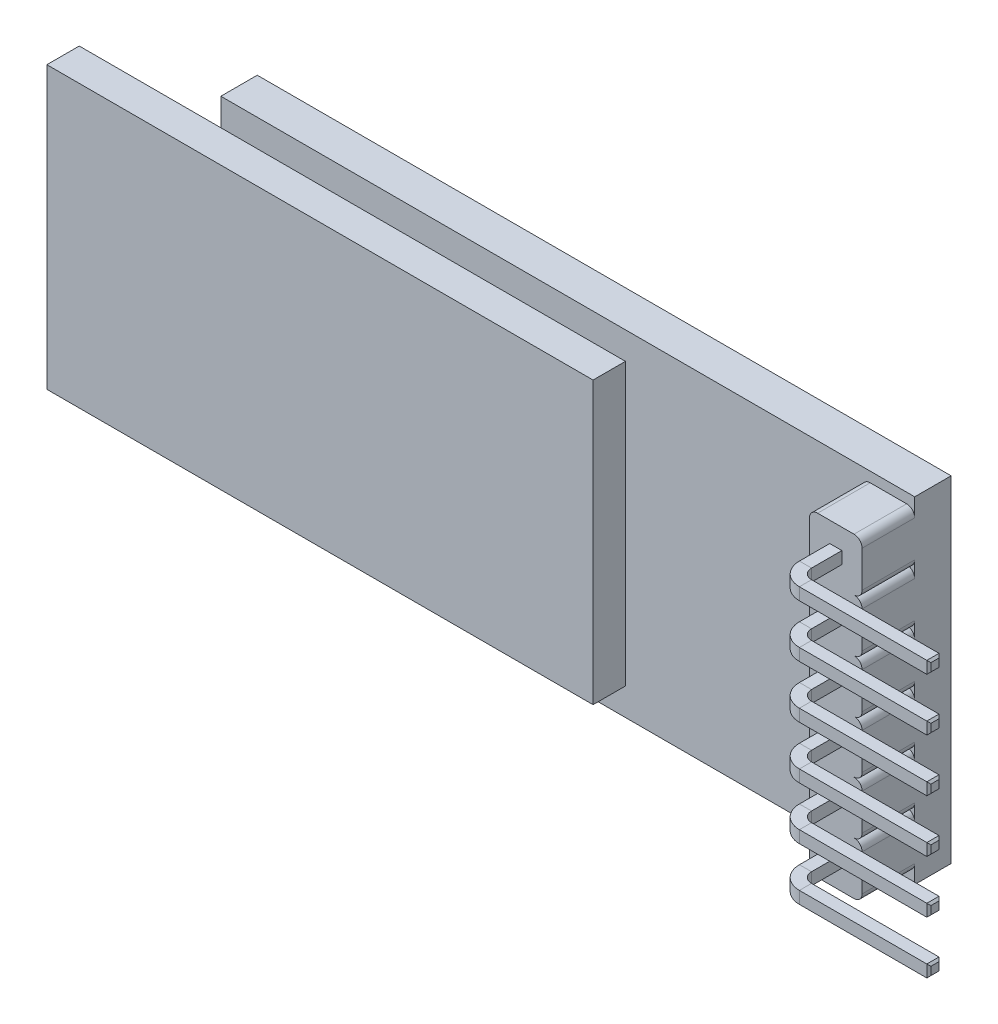
from build123d import *

# Parameters (mm, degrees)
SKETCH1_W                  = 34.3
SKETCH1_H                  = 16.6
BOSS_EXTRUDE1_DEPTH        = 1.8
SKETCH2_W                  = 27
SKETCH2_H                  = 13.9
BOSS_EXTRUDE2_DEPTH        = 1.6
BOSS_EXTRUDE3_DEPTH        = 2.6
LPATTERN1_COUNT            = 2
LPATTERN1_PITCH            = 7.8
SKETCH6_W                  = 0.6
SKETCH6_H                  = 0.6
CHAMFER1_SIZE              = 0.1
LPATTERN2_COUNT            = 6
LPATTERN2_PITCH            = 2.6
CHAMFER1_OF_LPATTERN2_SIZE = 0.1


with BuildPart() as part:
    # Sketch1 → Boss-Extrude1 (new body)
    with BuildSketch(Plane.XY):
        Rectangle(SKETCH1_W, SKETCH1_H)
    extrude(amount=-BOSS_EXTRUDE1_DEPTH)



with BuildPart() as body_2:
    # Sketch2 → Boss-Extrude2 (new body)
    with BuildSketch(Plane.XY):
        with Locations((-10.65, 0)):
            Rectangle(SKETCH2_W, SKETCH2_H)
    extrude(amount=BOSS_EXTRUDE2_DEPTH)


with BuildPart() as body_3:
    # Sketch3 → Boss-Extrude3 (new body)
    with BuildSketch(Plane.XY):
        with BuildLine():
            ThreePointArc((14.55, -2.2), (14.667157288, -2.482842712), (14.95, -2.6))
            Line((14.95, -2.6), (16.75, -2.6))
            ThreePointArc((16.75, -2.6), (17.032842712, -2.482842712), (17.15, -2.2))
            Line((17.15, -2.2), (17.15, -0.4))
            ThreePointArc((17.15, -0.4), (17.032842712, -0.117157288), (16.75, 0))
            Line((16.75, 0), (14.95, 0))
            ThreePointArc((14.95, 0), (14.667157288, -0.117157288), (14.55, -0.4))
            Line((14.55, -0.4), (14.55, -2.2))
        make_face()
        with BuildLine():
            Line((16.75, -2.6), (14.95, -2.6))
            ThreePointArc((14.95, -2.6), (14.667157288, -2.717157288), (14.55, -3))
            Line((14.55, -3), (14.55, -4.8))
            ThreePointArc((14.55, -4.8), (14.667157288, -5.082842712), (14.95, -5.2))
            Line((14.95, -5.2), (16.75, -5.2))
            ThreePointArc((16.75, -5.2), (17.032842712, -5.082842712), (17.15, -4.8))
            Line((17.15, -4.8), (17.15, -3))
            ThreePointArc((17.15, -3), (17.032842712, -2.717157288), (16.75, -2.6))
        make_face()
        with BuildLine():
            Line((16.75, -5.2), (14.95, -5.2))
            ThreePointArc((14.95, -5.2), (14.667157288, -5.317157288), (14.55, -5.6))
            Line((14.55, -5.6), (14.55, -7.4))
            ThreePointArc((14.55, -7.4), (14.667157288, -7.682842712), (14.95, -7.8))
            Line((14.95, -7.8), (16.75, -7.8))
            ThreePointArc((16.75, -7.8), (17.032842712, -7.682842712), (17.15, -7.4))
            Line((17.15, -7.4), (17.15, -5.6))
            ThreePointArc((17.15, -5.6), (17.032842712, -5.317157288), (16.75, -5.2))
        make_face()
    boss_extrude3 = extrude(amount=BOSS_EXTRUDE3_DEPTH)


with BuildPart() as lpattern1_1:
    # LPattern1: Boss-Extrude3 ×2
    with Locations(*[(0, i * LPATTERN1_PITCH, 0) for i in range(1, LPATTERN1_COUNT)]):
        add(boss_extrude3)


with BuildPart() as part_1:
    add(part.part)

    add(body_3.part)  # Sweep2 merges body 3
    # Sweep2: sweep along a path in Sketch5
    with BuildLine(Plane(origin=(0, -6.5, 0), x_dir=(-1, 0, 0), z_dir=(0, -1, 0))) as sweep2_path:
        Line((-23.05, -4.9), (-16.65, -4.9))
        ThreePointArc((-16.65, -4.9), (-16.084314575, -4.665685425), (-15.85, -4.1))
        Line((-15.85, -4.1), (-15.85, -2.6))
        Line((-15.85, -2.6), (-15.85, 2.9))
    # Sketch6 → Sweep2 (sweep)
    with BuildSketch(Plane(origin=(23.05, 0, 0), x_dir=(0, 0, -1), z_dir=(1, 0, 0))):
        with Locations((-4.9, -6.5)):
            Rectangle(SKETCH6_W, SKETCH6_H)
    sweep2 = sweep(path=sweep2_path.line)

    # Chamfer1
    chamfer1_edges = [part_1.edges().sort_by_distance(p)[0] for p in [
        (23.05, -6.5, 5.2),
        (23.05, -6.8, 4.9),
        (23.05, -6.5, 4.6),
        (23.05, -6.2, 4.9),
        (16.15, -6.5, -2.9),
        (15.85, -6.2, -2.9),
        (15.55, -6.5, -2.9),
        (15.85, -6.8, -2.9),
    ]]
    chamfer(chamfer1_edges, length=CHAMFER1_SIZE)


    add(lpattern1_1.part)  # LPattern2 merges LPattern1_1
    # LPattern2: Sweep2 ×6
    with Locations(*[(0, i * LPATTERN2_PITCH, 0) for i in range(1, LPATTERN2_COUNT)]):
        add(sweep2)

    # Chamfer1 of LPattern2
    chamfer1_of_lpattern2_edges = [part_1.edges().sort_by_distance(p)[0] for p in [
        (23.05, -3.9, 5.2),
        (23.05, -4.2, 4.9),
        (23.05, -3.9, 4.6),
        (23.05, -3.6, 4.9),
        (16.15, -3.9, -2.9),
        (15.85, -3.6, -2.9),
        (15.55, -3.9, -2.9),
        (15.85, -4.2, -2.9),
        (23.05, -1.3, 5.2),
        (23.05, -1.6, 4.9),
        (23.05, -1.3, 4.6),
        (23.05, -1, 4.9),
        (16.15, -1.3, -2.9),
        (15.85, -1, -2.9),
        (15.55, -1.3, -2.9),
        (15.85, -1.6, -2.9),
        (23.05, 1.3, 5.2),
        (23.05, 1, 4.9),
        (23.05, 1.3, 4.6),
        (23.05, 1.6, 4.9),
        (16.15, 1.3, -2.9),
        (15.85, 1.6, -2.9),
        (15.55, 1.3, -2.9),
        (15.85, 1, -2.9),
        (23.05, 3.9, 5.2),
        (23.05, 3.6, 4.9),
        (23.05, 3.9, 4.6),
        (23.05, 4.2, 4.9),
        (16.15, 3.9, -2.9),
        (15.85, 4.2, -2.9),
        (15.55, 3.9, -2.9),
        (15.85, 3.6, -2.9),
        (23.05, 6.5, 5.2),
        (23.05, 6.2, 4.9),
        (23.05, 6.5, 4.6),
        (23.05, 6.8, 4.9),
        (16.15, 6.5, -2.9),
        (15.85, 6.8, -2.9),
        (15.55, 6.5, -2.9),
        (15.85, 6.2, -2.9),
    ]]
    chamfer(chamfer1_of_lpattern2_edges, length=CHAMFER1_OF_LPATTERN2_SIZE)


solid = Compound([body_2.part, part_1.part])
